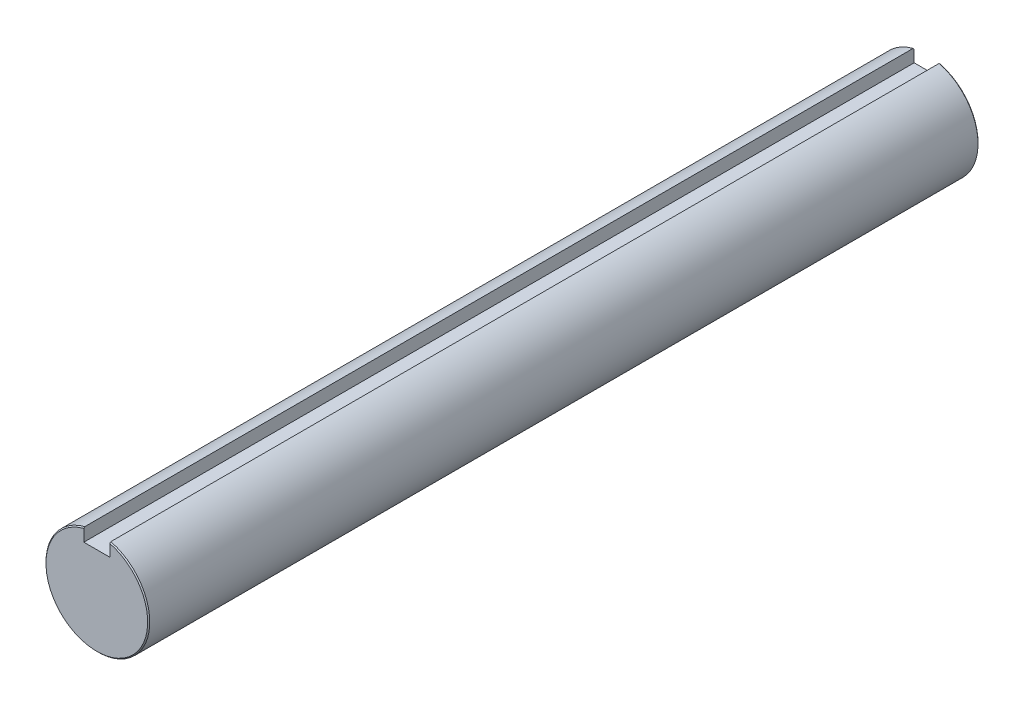
from build123d import *

# Parameters (mm, degrees)
BOSS_EXTRUDE1_DEPTH      = 38.1
BOSS_EXTRUDE1_DEPTH_BACK = 38.1
CHAMFER1_SIZE            = 0.09525


with BuildPart() as part:
    # Sketch3 → Boss-Extrude1 (new body, two sides)
    with BuildSketch(Plane.XY) as boss_extrude1_sk:
        with BuildLine():
            Line((-1.1938, 3.416649849), (-1.1938, 4.610449849))
            ThreePointArc((-1.1938, 4.610449849), (0, -4.7625), (1.1938, 4.610449849))
            Line((1.1938, 4.610449849), (1.1938, 3.416649849))
            Line((1.1938, 3.416649849), (-1.1938, 3.416649849))
        make_face()
    extrude(amount=BOSS_EXTRUDE1_DEPTH)
    extrude(boss_extrude1_sk.sketch, amount=-BOSS_EXTRUDE1_DEPTH_BACK)

    # Chamfer1
    chamfer1_edges = [part.edges().sort_by_distance(p)[0] for p in [
        (0, -4.7625, -38.1),
        (0, -4.7625, 38.1),
    ]]
    chamfer(chamfer1_edges, length=CHAMFER1_SIZE)


solid = part.part
